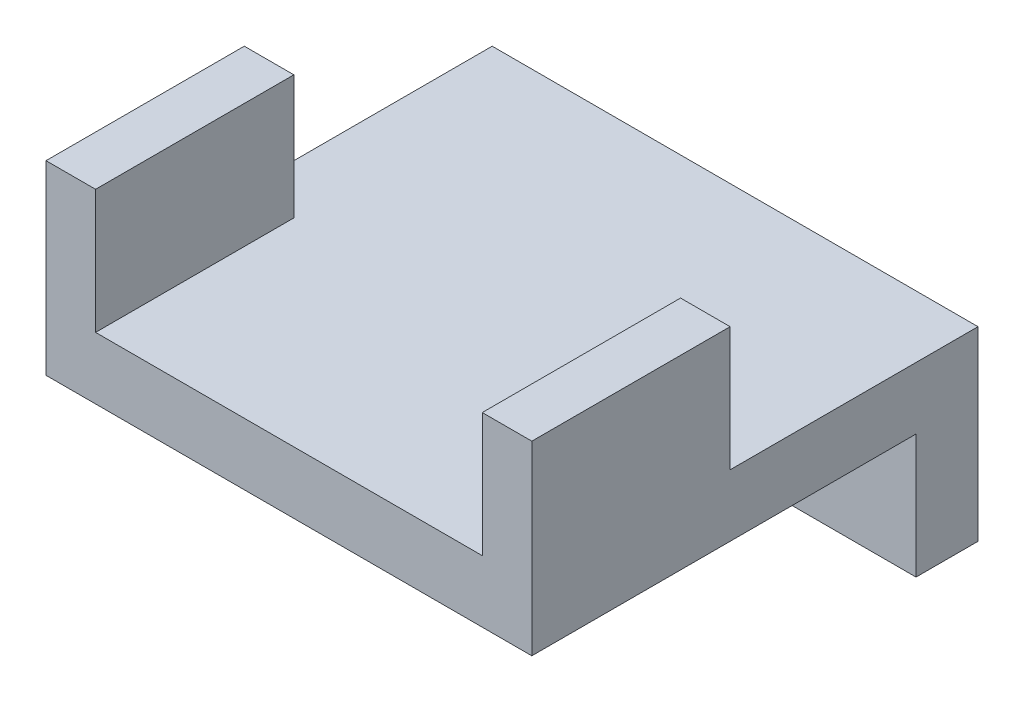
from build123d import *

# Parameters (mm, degrees)
SKETCH2_W           = 24.892
SKETCH2_H           = 22.86
BOSS_EXTRUDE1_DEPTH = 3.175
SKETCH3_W           = 2.54
SKETCH3_H           = 10.16
BOSS_EXTRUDE2_DEPTH = 6.35
SKETCH4_W           = 24.892
SKETCH4_H           = 3.175
BOSS_EXTRUDE3_DEPTH = 6.35


with BuildPart() as part:
    # Sketch2 → Boss-Extrude1 (new body)
    with BuildSketch(Plane(origin=(0, 0, 0), x_dir=(1, 0, 0), z_dir=(0, 1, 0))):
        Rectangle(SKETCH2_W, SKETCH2_H)
    extrude(amount=BOSS_EXTRUDE1_DEPTH)

    # Sketch3 → Boss-Extrude2 (add)
    with BuildSketch(Plane(origin=(0, 3.175, 0), x_dir=(1, 0, 0), z_dir=(0, 1, 0))):
        with Locations((11.176, -6.35)):
            Rectangle(SKETCH3_W, SKETCH3_H)
        with Locations((-11.176, -6.35)):
            Rectangle(SKETCH3_W, SKETCH3_H)
    extrude(amount=BOSS_EXTRUDE2_DEPTH)

    # Sketch4 → Boss-Extrude3 (add)
    with BuildSketch(Plane.XZ):
        with Locations((0, -9.8425)):
            Rectangle(SKETCH4_W, SKETCH4_H)
    extrude(amount=BOSS_EXTRUDE3_DEPTH)


solid = part.part
